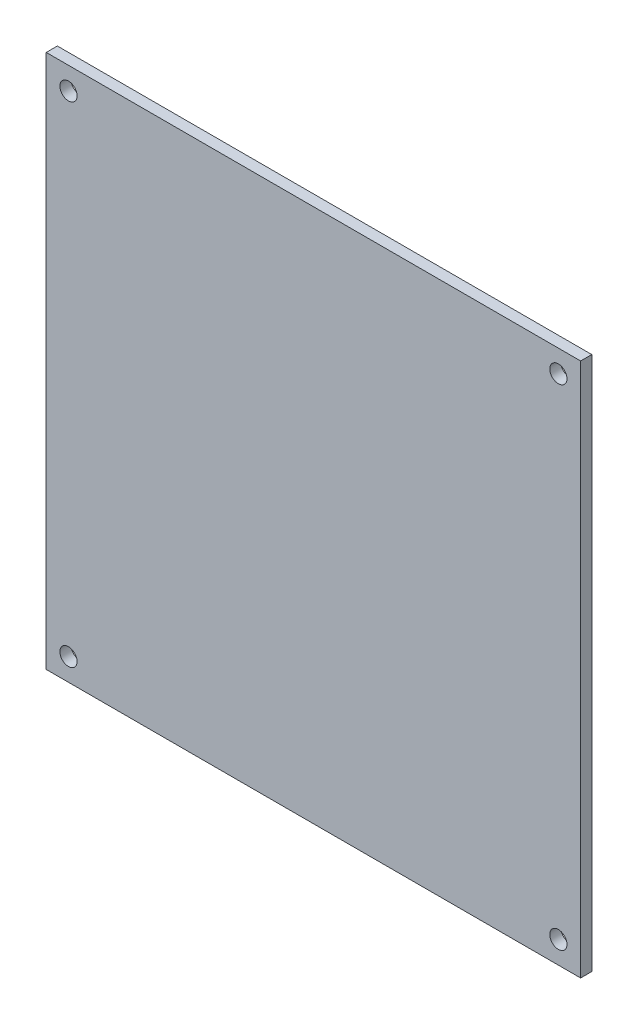
from build123d import *

# Parameters (mm, degrees)
SKETCH1_W                    = 152.4
SKETCH1_H                    = 152.4
BOSS_EXTRUDE1_DEPTH          = 3.175
F_10_0_1935_DIAMETER_HOLE1_D = 4.9149


with BuildPart() as part:
    # Sketch1 → Boss-Extrude1 (new body)
    with BuildSketch(Plane.XY):
        Rectangle(SKETCH1_W, SKETCH1_H)
    extrude(amount=BOSS_EXTRUDE1_DEPTH)

    # #10 (0.1935) Diameter Hole1 (through all)
    with Locations(Plane.XY.offset(3.175)):
        with Locations((69.85, -69.85), (-69.85, -69.85), (-69.85, 69.85), (69.85, 69.85)):
            Hole(F_10_0_1935_DIAMETER_HOLE1_D / 2)


solid = part.part
